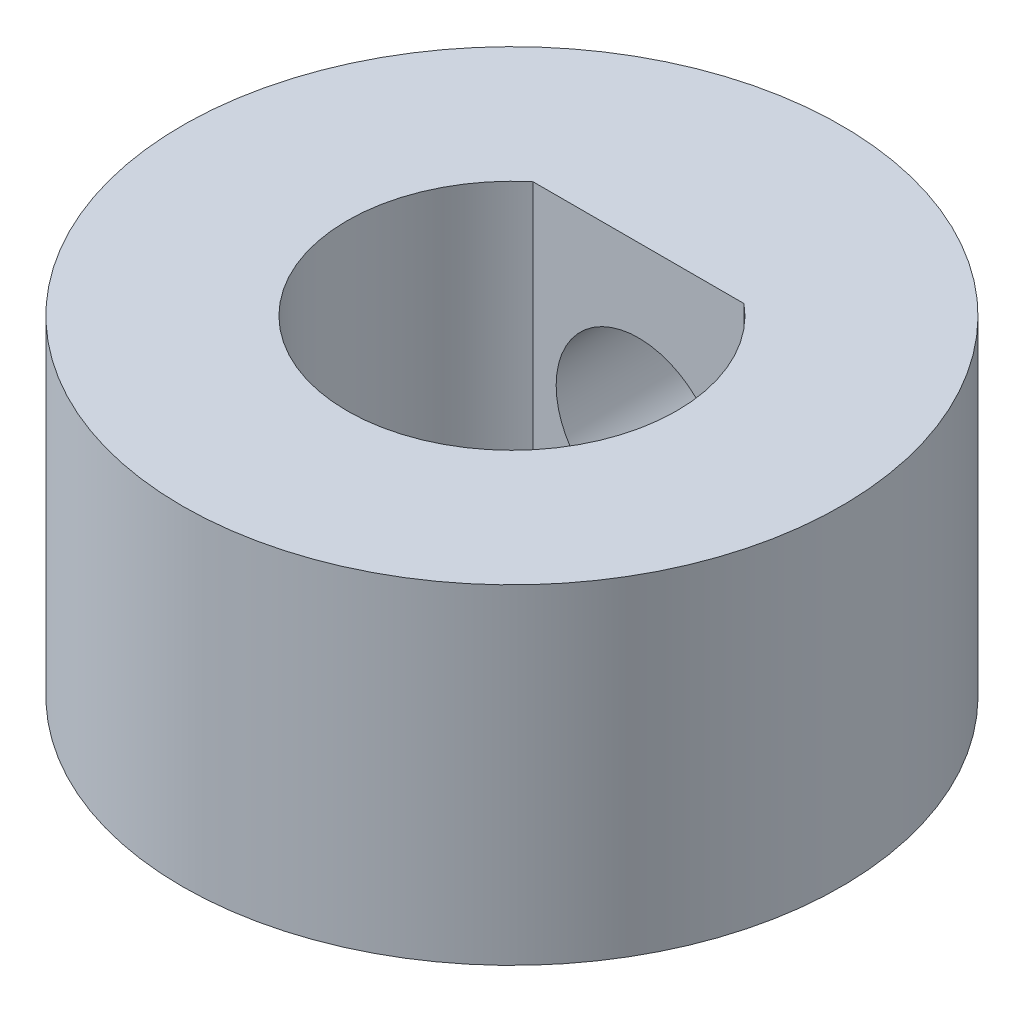
from build123d import *

# Parameters (mm, degrees)
SKETCH1_R           = 6.35
BOSS_EXTRUDE1_DEPTH = 6.35
CUT_EXTRUDE1_REACH  = 14.7
SKETCH3_R           = 1.5875


with BuildPart() as part:
    # Sketch1 → Boss-Extrude1 (new body)
    with BuildSketch(Plane(origin=(0, 0, 0), x_dir=(1, 0, 0), z_dir=(0, 1, 0))):
        Circle(SKETCH1_R)
        with BuildLine():
            Line((-2.032, 2.439590334), (2.032, 2.439590334))
            ThreePointArc((2.032, 2.439590334), (0, -3.175), (-2.032, 2.439590334))
        make_face(mode=Mode.SUBTRACT)
    extrude(amount=BOSS_EXTRUDE1_DEPTH)

    # Sketch3 → Cut-Extrude1 (cut, up to next)
    with BuildSketch(Plane(origin=(0, 0, -6.35), x_dir=(-1, 0, 0), z_dir=(0, 0, -1)), mode=Mode.PRIVATE) as cut_extrude1_sk1:
        with Locations((0, 3.175)):
            Circle(SKETCH3_R)
    cut_extrude1_tool1 = extrude(cut_extrude1_sk1.sketch, amount=-CUT_EXTRUDE1_REACH, mode=Mode.PRIVATE) & part.part
    add(cut_extrude1_tool1.solids().sort_by_distance((0, 3.175, -6.35))[0], mode=Mode.SUBTRACT)


solid = part.part
